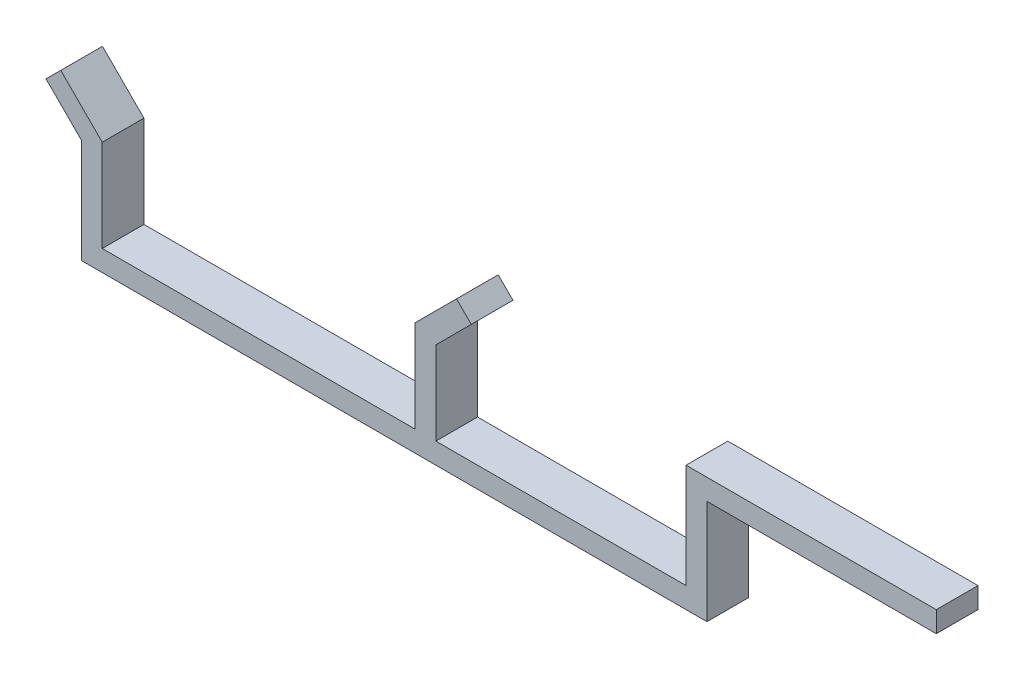
from build123d import *

# Parameters (mm, degrees)
BOSS_EXTRUDE1_DEPTH = 10


with BuildPart() as part:
    # Sketch1 → Boss-Extrude1 (new body)
    with BuildSketch(Plane.XY):
        Polygon((-42.5, 8.635239362), (-42.5, -16.364760638), (107.5, -16.364760638), (107.5, 8.635239362), (162.5, 8.635239362), (162.5, 13.635239362), (102.5, 13.635239362), (102.5, -11.364760638), (42.5, -11.364760638), (42.5, 8.635239362), (50.985281374, 17.120520736), (47.449747468, 20.656054642), (37.5, 10.706307174), (37.5, 8.635239362), (37.5, -11.364760638), (-37.5, -11.364760638), (-37.5, 8.635239362), (-37.5, 10.706307174), (-47.449747468, 20.656054642), (-50.985281374, 17.120520736), align=None)
    extrude(amount=BOSS_EXTRUDE1_DEPTH)


solid = part.part
